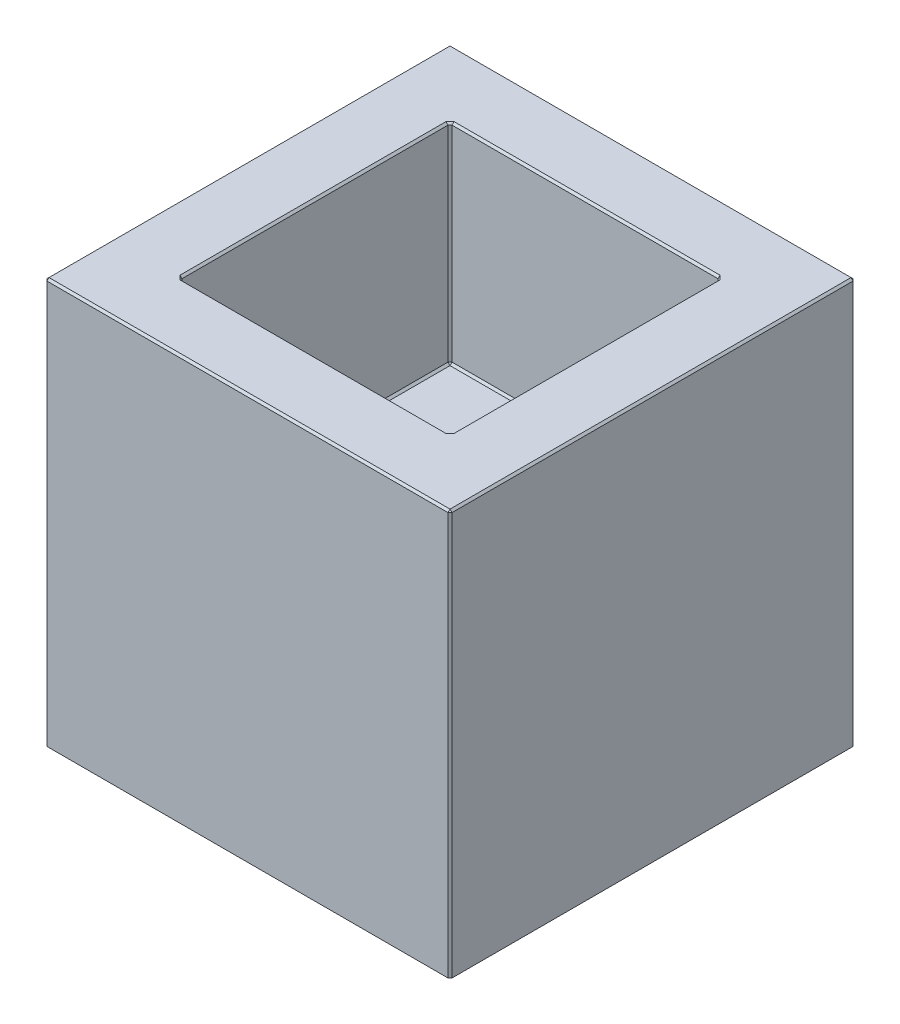
from build123d import *

# Parameters (mm, degrees)
ESQUISSE2_W             = 6
ESQUISSE2_H             = 6
BOSS_EXTRU_1_DEPTH      = 6
ESQUISSE4_W             = 4
ESQUISSE4_H             = 4
ENL_V_MAT_EXTRU_1_DEPTH = 3.1
CHANFREIN1_SIZE         = 0.03


with BuildPart() as part:
    # Esquisse2 → Boss.-Extru.1 (new body)
    with BuildSketch(Plane(origin=(0, 0, 0), x_dir=(1, 0, 0), z_dir=(0, 1, 0))):
        Rectangle(ESQUISSE2_W, ESQUISSE2_H)
    extrude(amount=BOSS_EXTRU_1_DEPTH)

    # Esquisse4 → Enlèv. mat.-Extru.1 (cut)
    with BuildSketch(Plane(origin=(0, 6, 0), x_dir=(1, 0, 0), z_dir=(0, 1, 0))):
        Rectangle(ESQUISSE4_W, ESQUISSE4_H)
    extrude(amount=-ENL_V_MAT_EXTRU_1_DEPTH, mode=Mode.SUBTRACT)

    # Chanfrein1
    chanfrein1_edges = [part.edges().sort_by_distance(p)[0] for p in [
        (-3, 6, 0),
        (2, 2.9, 0),
        (2, 4.45, -2),
        (0, 6, 3),
        (0, 2.9, 2),
        (2, 4.45, 2),
        (-2, 2.9, 0),
        (-2, 4.45, 2),
        (0, 2.9, -2),
        (-2, 4.45, -2),
        (2, 6, 0),
        (0, 6, -2),
        (-2, 6, 0),
        (0, 6, 2),
        (3, 6, 0),
        (3, 3, 3),
        (-3, 3, 3),
        (-3, 3, -3),
        (3, 3, -3),
        (0, 6, -3),
    ]]
    chamfer(chanfrein1_edges, length=CHANFREIN1_SIZE)


solid = part.part
